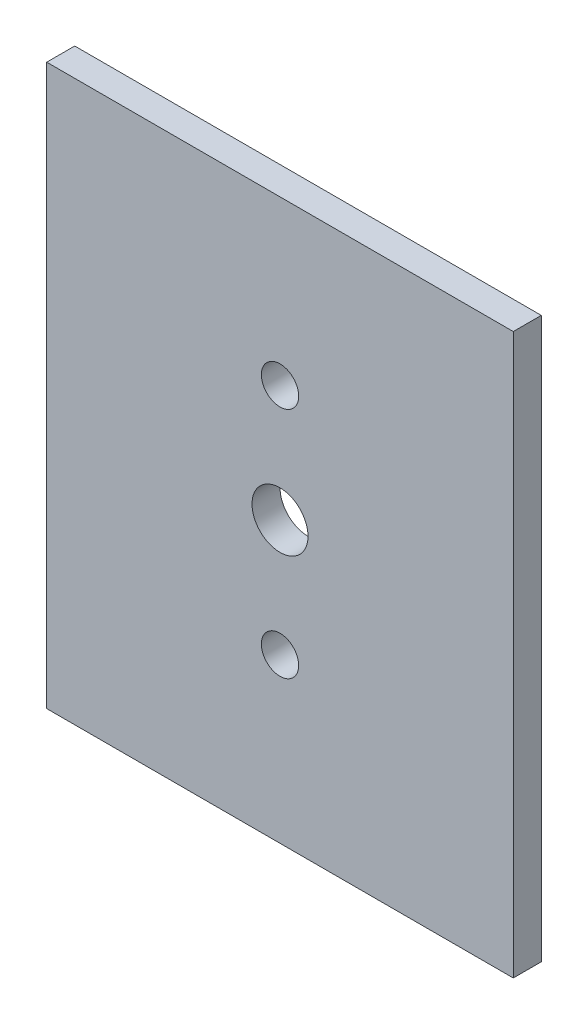
from build123d import *

# Parameters (mm, degrees)
SKETCH1_W           = 50
SKETCH1_H           = 60
SKETCH1_R           = 3
BOSS_EXTRUDE1_DEPTH = 3
SKETCH2_R           = 2
CUT_EXTRUDE1_DEPTH  = 4


with BuildPart() as part:
    # Sketch1 → Boss-Extrude1 (new body)
    with BuildSketch(Plane.XY):
        Rectangle(SKETCH1_W, SKETCH1_H)
        Circle(SKETCH1_R, mode=Mode.SUBTRACT)
    extrude(amount=BOSS_EXTRUDE1_DEPTH)

    # Sketch2 → Cut-Extrude1 (cut, through all)
    with BuildSketch(Plane(origin=(0, 0, 0), x_dir=(-1, 0, 0), z_dir=(0, 0, -1))):
        with Locations((0, 12.5)):
            Circle(SKETCH2_R)
        with Locations((0, -12.5)):
            Circle(SKETCH2_R)
    extrude(amount=-CUT_EXTRUDE1_DEPTH, mode=Mode.SUBTRACT)


solid = part.part
